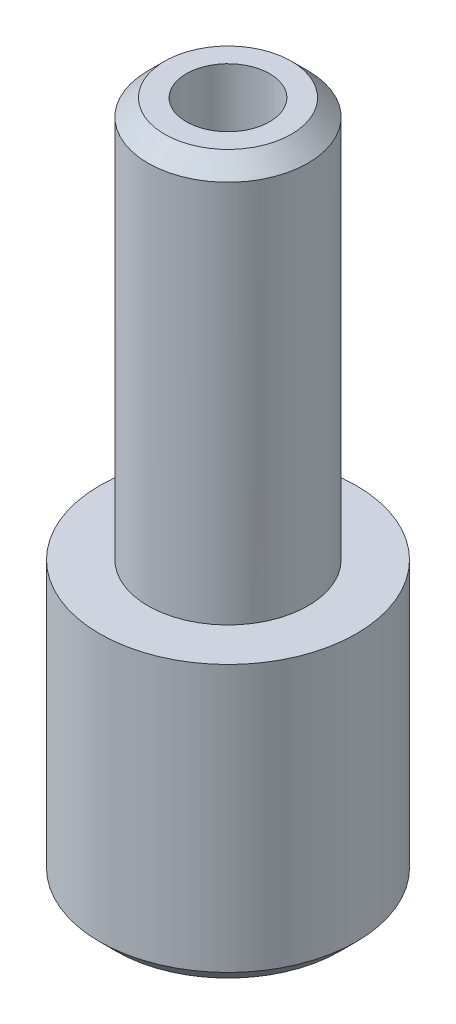
from build123d import *

# Parameters (mm, degrees)
CHAMFER1_SIZE = 0.5


with BuildPart() as part:
    # Sketch1 → Revolve1 (revolve)
    with BuildSketch(Plane.XY):
        Polygon((1.25, 0), (1.25, 20.5), (2.4, 20.5), (2.4, 8.5), (3.85, 8.5), (3.85, 0), align=None)
    revolve(axis=Axis((0, 9.717567568, 0), (0, -1, 0)))

    # Chamfer1
    chamfer1_edges = [part.edges().sort_by_distance(p)[0] for p in [
        (-3.85, 0, 0),
        (-2.4, 20.5, 0),
    ]]
    chamfer(chamfer1_edges, length=CHAMFER1_SIZE)


solid = part.part
